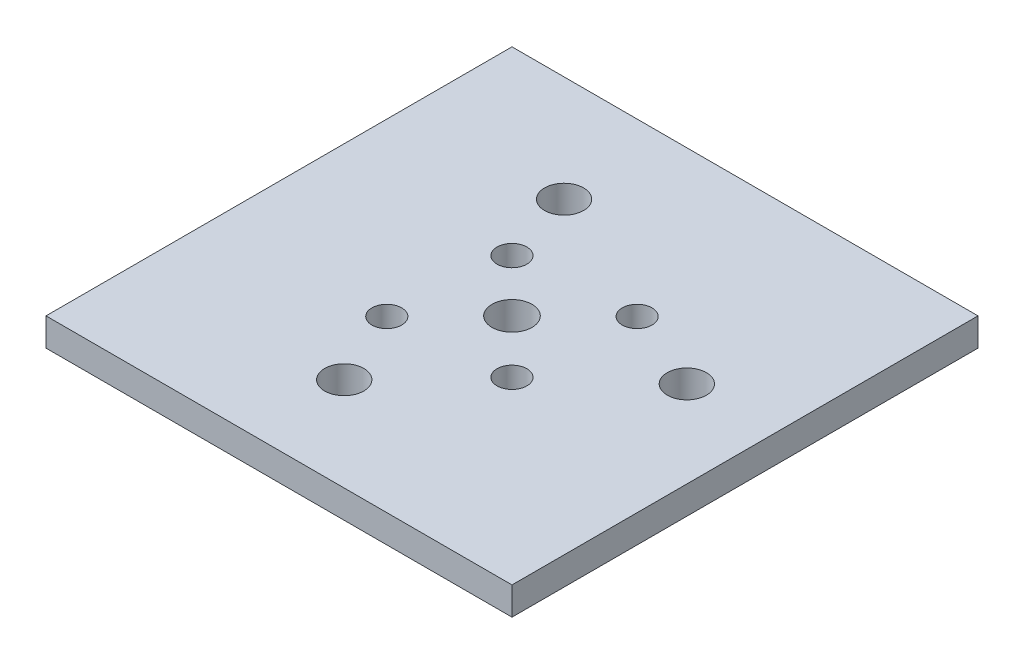
from build123d import *

# Parameters (mm, degrees)
SKETCH1_W           = 50
SKETCH1_H           = 50
BOSS_EXTRUDE1_DEPTH = 3
SKETCH2_R           = 2.15
CUT_EXTRUDE1_DEPTH  = 4
SKETCH3_R           = 1.6
CUT_EXTRUDE2_DEPTH  = 4
SKETCH4_R           = 2.1
CUT_EXTRUDE3_DEPTH  = 4


with BuildPart() as part:
    # Sketch1 → Boss-Extrude1 (new body)
    with BuildSketch(Plane(origin=(0, 0, 0), x_dir=(1, 0, 0), z_dir=(0, 1, 0))):
        Rectangle(SKETCH1_W, SKETCH1_H)
    extrude(amount=-BOSS_EXTRUDE1_DEPTH)

    # Sketch2 → Cut-Extrude1 (cut, through all)
    with BuildSketch(Plane(origin=(0, 0, 0), x_dir=(1, 0, 0), z_dir=(0, 1, 0))):
        Circle(SKETCH2_R)
    extrude(amount=-CUT_EXTRUDE1_DEPTH, mode=Mode.SUBTRACT)

    # Sketch3 → Cut-Extrude2 (cut, through all)
    with BuildSketch(Plane(origin=(0, 0, 0), x_dir=(1, 0, 0), z_dir=(0, 1, 0))):
        with Locations((6.768353811, 6.657078174)):
            Circle(SKETCH3_R)
        with Locations((-6.661646189, -6.772921826)):
            Circle(SKETCH3_R)
        with Locations((-5.601646189, 5.597078174)):
            Circle(SKETCH3_R)
        with Locations((5.708353811, -5.712921826)):
            Circle(SKETCH3_R)
    extrude(amount=-CUT_EXTRUDE2_DEPTH, mode=Mode.SUBTRACT)

    # Sketch4 → Cut-Extrude3 (cut, through all)
    with BuildSketch(Plane(origin=(0, 0, 0), x_dir=(1, 0, 0), z_dir=(0, 1, 0))):
        with Locations((15.70537943, 3.056314275)):
            Circle(SKETCH4_R)
        with Locations((-3.064333665, -14.935291276)):
            Circle(SKETCH4_R)
        with Locations((-8.045828007, 13.633655399)):
            Circle(SKETCH4_R)
    extrude(amount=-CUT_EXTRUDE3_DEPTH, mode=Mode.SUBTRACT)


solid = part.part
